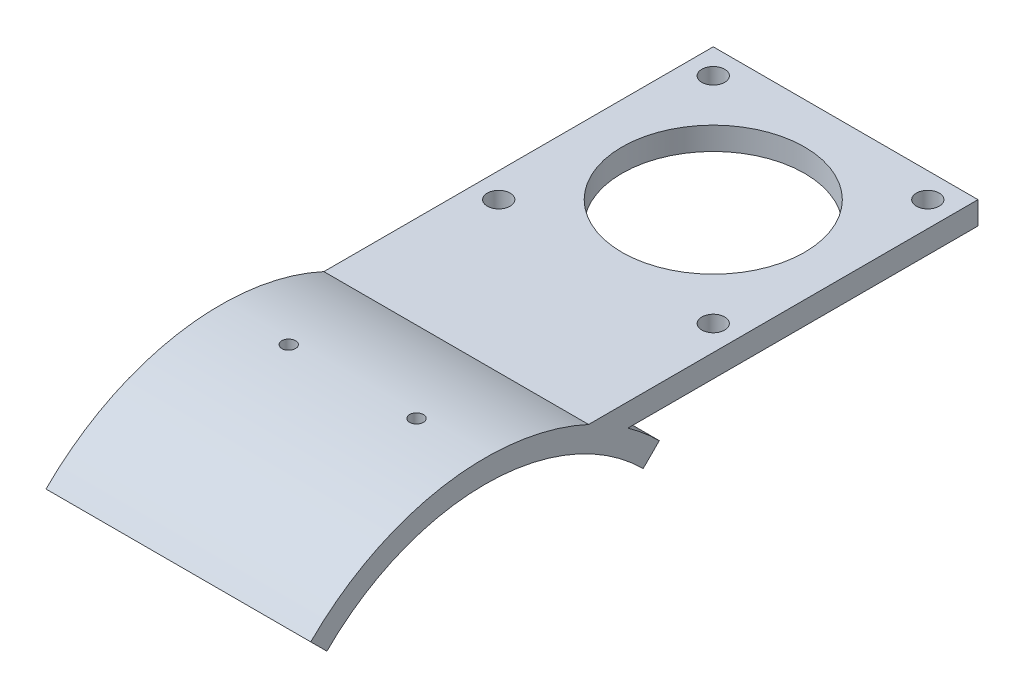
from build123d import *

# Parameters (mm, degrees)
BOSS_EXTRUDE2_DEPTH     = 58
SKETCH6_R               = 2.5
SKETCH6_R_2             = 20
CUT_EXTRUDE3_DEPTH      = 58
CUT_EXTRUDE4_DEPTH      = 58
CUT_EXTRUDE4_DEPTH_BACK = 58
SKETCH7_R               = 1.5


with BuildPart() as part:
    # Sketch5 → Boss-Extrude2 (new body)
    with BuildSketch(Plane(origin=(0, 0, 0), x_dir=(0, 0, -1), z_dir=(1, 0, 0))):
        with BuildLine():
            Line((108, 0), (108, -5))
            Line((108, -5), (31.304951685, -5))
            ThreePointArc((31.304951685, -5), (34.8658518, -7.764428241), (38.183766184, -10.816233816))
            Line((38.183766184, -10.816233816), (34.648232278, -14.351767722))
            ThreePointArc((34.648232278, -14.351767722), (18.751488186, -3.729902907), (0, 0))
            ThreePointArc((0, 0), (-18.751488186, -3.729902907), (-34.648232278, -14.351767722))
            Line((-34.648232278, -14.351767722), (-38.183766184, -10.816233816))
            ThreePointArc((-38.183766184, -10.816233816), (-20.664905348, 0.889494756), (0, 5))
            ThreePointArc((0, 5), (11.618950039, 3.735187494), (22.693611436, 0))
            Line((22.693611436, 0), (108, 0))
        make_face()
    extrude(amount=BOSS_EXTRUDE2_DEPTH)

    # Sketch6 → Cut-Extrude3 (cut)
    with BuildSketch(Plane(origin=(0, 0, 0), x_dir=(1, 0, 0), z_dir=(0, 1, 0))):
        with Locations((5.5, 102.5)):
            Circle(SKETCH6_R)
        with Locations((52.5, 102.5)):
            Circle(SKETCH6_R)
        with Locations((52.5, 55.5)):
            Circle(SKETCH6_R)
        with Locations((5.5, 55.5)):
            Circle(SKETCH6_R)
        with Locations((29, 79)):
            Circle(SKETCH6_R_2)
    extrude(amount=-CUT_EXTRUDE3_DEPTH, mode=Mode.SUBTRACT)

    # Sketch7 → Cut-Extrude4 (cut, two sides: drawn at the far end of the back side and taken through both)
    with BuildSketch(Plane(origin=(0, 0, 0), x_dir=(1, 0, 0), z_dir=(0, 1, 0)).offset(-CUT_EXTRUDE4_DEPTH_BACK)):
        with Locations((15, 0)):
            Circle(SKETCH7_R)
        with Locations((43, 0)):
            Circle(SKETCH7_R)
    extrude(amount=CUT_EXTRUDE4_DEPTH + CUT_EXTRUDE4_DEPTH_BACK, mode=Mode.SUBTRACT)


solid = part.part
